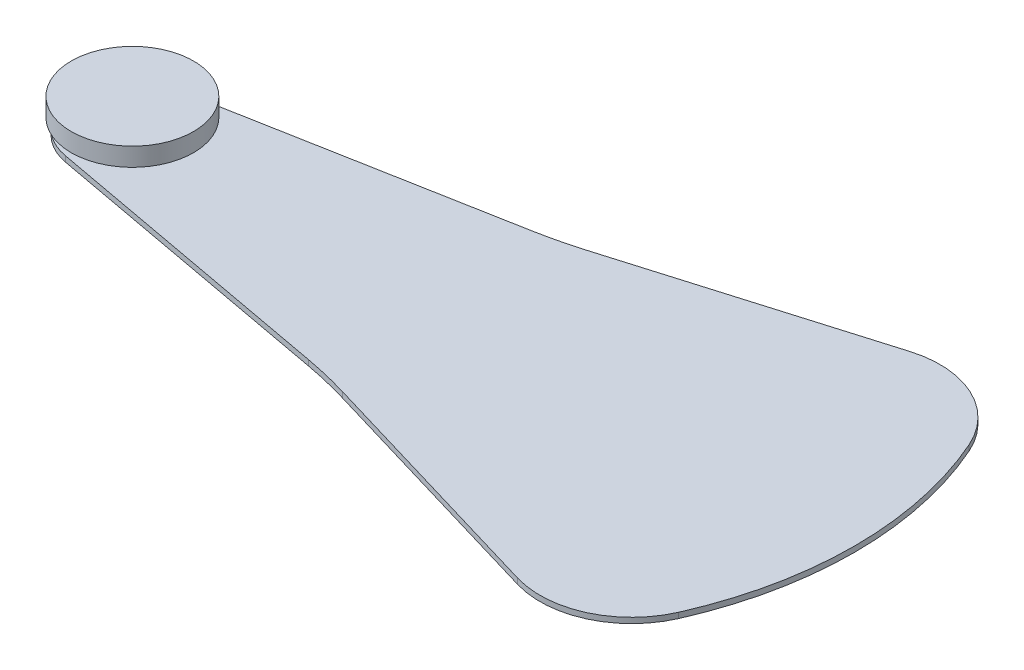
from build123d import *

# Parameters (mm, degrees)
BOSS_EXTRUDE2_DEPTH = 0.18
SKETCH4_R           = 1
CUT_EXTRUDE1_DEPTH  = 1.18
SKETCH7_R           = 2
BOSS_EXTRUDE3_DEPTH = 0.6
SKETCH8_R           = 1.4
SKETCH8_R_2         = 1
BOSS_EXTRUDE4_DEPTH = 0.93


with BuildPart() as part:
    # Sketch2 → Boss-Extrude2 (new body)
    with BuildSketch(Plane.XZ.offset(-113.480952772)):
        with BuildLine():
            Line((60.372883835, 72.194540047), (70.125446667, 70.394451024))
            ThreePointArc((70.125446667, 70.394451024), (70.859385482, 70.238798062), (71.58406324, 70.044540047))
            Line((71.58406324, 70.044540047), (79.733100179, 67.627269484))
            ThreePointArc((79.733100179, 67.627269484), (81.847875106, 67.781237193), (83.333100179, 69.294540047))
            ThreePointArc((83.333100179, 69.294540047), (84.080389833, 71.617479067), (84.333100179, 74.044540047))
            ThreePointArc((84.333100179, 74.044540047), (84.080389833, 76.471601027), (83.333100179, 78.794540047))
            ThreePointArc((83.333100179, 78.794540047), (81.847875106, 80.307842901), (79.733100179, 80.46181061))
            Line((79.733100179, 80.46181061), (71.58406324, 78.044540047))
            ThreePointArc((71.58406324, 78.044540047), (70.859385482, 77.850282031), (70.125446667, 77.69462907))
            Line((70.125446667, 77.69462907), (60.372883835, 75.894540047))
            ThreePointArc((60.372883835, 75.894540047), (58.833100179, 74.044540047), (60.372883835, 72.194540047))
        make_face()
    extrude(amount=-BOSS_EXTRUDE2_DEPTH)

    # Sketch4 → Cut-Extrude1 (cut, through all)
    with BuildSketch(Plane.XZ.offset(-113.480952772)):
        with Locations((60.714349432, 74.044540047)):
            Circle(SKETCH4_R)
    extrude(amount=-CUT_EXTRUDE1_DEPTH, mode=Mode.SUBTRACT)



with BuildPart() as body_2:
    # Sketch7 → Boss-Extrude3 (new body)
    with BuildSketch(Plane(origin=(0, 113.990952772, 0), x_dir=(1, 0, 0), z_dir=(0, 1, 0))):
        with Locations((60.714349432, -74.044540047)):
            Circle(SKETCH7_R)
    extrude(amount=BOSS_EXTRUDE3_DEPTH)


with BuildPart() as part_1:
    add(part.part)

    add(body_2.part)  # Boss-Extrude4 merges body 2
    # Sketch8 → Boss-Extrude4 (add)
    with BuildSketch(Plane(origin=(0, 113.660952772, 0), x_dir=(1, 0, 0), z_dir=(0, 1, 0))):
        with Locations((60.714349432, -74.044540047)):
            Circle(SKETCH8_R)
        with Locations((60.714349432, -74.044540047)):
            Circle(SKETCH8_R_2, mode=Mode.SUBTRACT)
    extrude(amount=BOSS_EXTRUDE4_DEPTH)


solid = part_1.part
